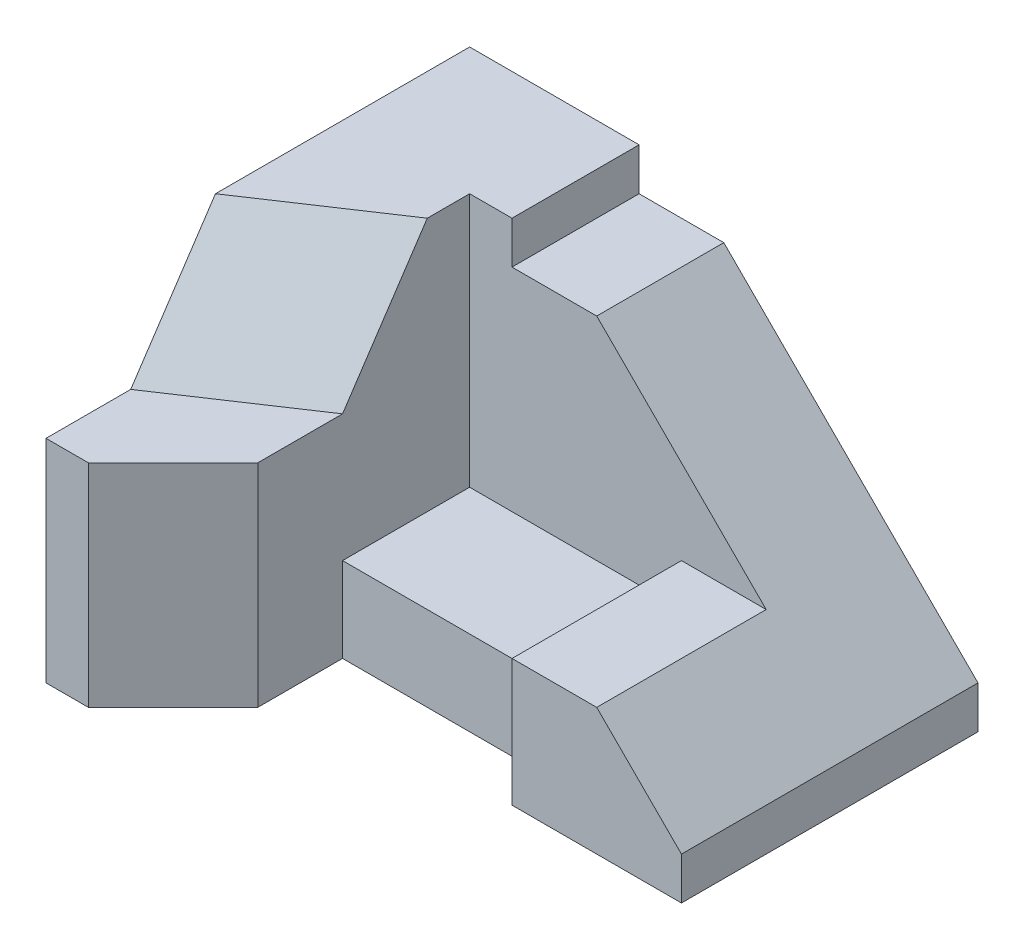
from build123d import *

# Parameters (mm, degrees)
BOSS_EXTRUDE1_DEPTH       = 80
SKETCH2_W                 = 60
SKETCH2_H                 = 80
BOSS_EXTRUDE6_DEPTH       = 10
CUT_EXTRUDE3_DEPTH        = 149
BOSS_EXTRUDE7_DEPTH       = 20
SKETCH11_W                = 100
SKETCH11_H                = 80
CUT_EXTRUDE4_DEPTH        = 20
CUT_EXTRUDE5_DEPTH        = 20
SKETCH14_W                = 24.037008503
SKETCH14_H                = 50
CUT_EXTRUDE6_DEPTH        = 29
SKETCH15_W                = 46.666666667
SKETCH15_H                = 50
CUT_EXTRUDE7_DEPTH        = 29
SKETCH16_W                = 20
SKETCH16_H                = 30
BOSS_EXTRUDE8_DEPTH       = 70
BOSS_EXTRUDE10_DEPTH      = 30
SKETCH21_W                = 43.205783384
SKETCH21_H                = 74.052806938
CUT_EXTRUDE9_DEPTH        = 30
SKETCH22_W                = 30
SKETCH22_H                = 20
CUT_EXTRUDE10_DEPTH       = 30
BOSS_EXTRUDE11_DEPTH      = 30
BOSS_EXTRUDE12_DEPTH      = 40
BOSS_EXTRUDE12_DEPTH_BACK = 30
SKETCH25_W                = 50
SKETCH25_H                = 20
BOSS_EXTRUDE13_DEPTH      = 60
BOSS_EXTRUDE16_DEPTH      = 50
BOSS_EXTRUDE17_DEPTH      = 20


with BuildPart() as part:
    # Sketch1 → Boss-Extrude1 (new body)
    with BuildSketch(Plane(origin=(0, 0, 0), x_dir=(1, 0, 0), z_dir=(0, 1, 0))):
        Polygon((0, 0), (0, 60), (40, 60), (40, 30), (30, 30), (30, 20), align=None)
    extrude(amount=BOSS_EXTRUDE1_DEPTH)

    # Sketch2 → Boss-Extrude6 (add)
    with BuildSketch(Plane.ZY):
        with Locations((-30, 40)):
            Rectangle(SKETCH2_W, SKETCH2_H)
        Polygon((40, 0), (0, 0), (0, 80), (20, 50), (40, 50), align=None)
    extrude(amount=-BOSS_EXTRUDE6_DEPTH)

    # Sketch8 → Cut-Extrude3 (cut)
    with BuildSketch(Plane(origin=(18.823529412, 18.823529412, 28.235294118), x_dir=(0.874474632, -0.269069118, -0.403603676), z_dir=(0.48507125, 0.48507125, 0.727606875))):
        Polygon((-21.525529408, 30.508510792), (12.780783086, 41.602514717), (12.780783086, 77.658027472), (-21.525529408, 66.564023547), align=None)
    extrude(amount=CUT_EXTRUDE3_DEPTH, mode=Mode.SUBTRACT)

    # Sketch10 → Boss-Extrude7 (add)
    with BuildSketch(Plane(origin=(18.823529412, 18.823529412, 28.235294118), x_dir=(0.874474632, -0.269069118, -0.403603676), z_dir=(0.48507125, 0.48507125, 0.727606875))):
        Polygon((-21.525529408, 30.508510792), (12.780783086, 41.602514717), (12.780783086, 77.658027472), (-21.525529408, 66.564023547), align=None)
    extrude(amount=-BOSS_EXTRUDE7_DEPTH)

    # Sketch11 → Cut-Extrude4 (cut)
    with BuildSketch(Plane.ZY):
        with Locations((-10, 40)):
            Rectangle(SKETCH11_W, SKETCH11_H)
    extrude(amount=CUT_EXTRUDE4_DEPTH, mode=Mode.SUBTRACT)

    # Sketch12 → Cut-Extrude5 (cut)
    with BuildSketch(Plane(origin=(0, 50, 0), x_dir=(1, 0, 0), z_dir=(0, 1, 0))):
        Polygon((0, -20), (10, -13.333333333), (10, -40), (0, -40), align=None)
    extrude(amount=CUT_EXTRUDE5_DEPTH, mode=Mode.SUBTRACT)

    # Sketch14 → Cut-Extrude6 (cut)
    with BuildSketch(Plane(origin=(0, 0, 0), x_dir=(0.832050294, 0, -0.554700196), z_dir=(0.554700196, 0, 0.832050294))):
        with Locations((24.037008504, 25)):
            Rectangle(SKETCH14_W, SKETCH14_H)
    extrude(amount=CUT_EXTRUDE6_DEPTH, mode=Mode.SUBTRACT)

    # Sketch15 → Cut-Extrude7 (cut)
    with BuildSketch(Plane(origin=(10, 0, 0), x_dir=(0, 0, -1), z_dir=(1, 0, 0))):
        with Locations((-16.666666666, 25)):
            Rectangle(SKETCH15_W, SKETCH15_H)
    extrude(amount=CUT_EXTRUDE7_DEPTH, mode=Mode.SUBTRACT)

    # Sketch16 → Boss-Extrude8 (add)
    with BuildSketch(Plane(origin=(0, 70, 0), x_dir=(1, 0, 0), z_dir=(0, 1, 0))):
        with Locations((50, 45)):
            Rectangle(SKETCH16_W, SKETCH16_H)
    extrude(amount=-BOSS_EXTRUDE8_DEPTH)

    # Sketch17 → Boss-Extrude10 (add)
    with BuildSketch(Plane(origin=(0, 0, -60), x_dir=(-1, 0, 0), z_dir=(0, 0, -1))):
        Polygon((-80, 10), (-80, 0), (-60, 0), (-60, 70), (-100, 10), align=None)
    extrude(amount=-BOSS_EXTRUDE10_DEPTH)

    # Sketch21 → Cut-Extrude9 (cut)
    with BuildSketch(Plane.XY.offset(-30)):
        with Locations((81.602891692, 32.973596531)):
            Rectangle(SKETCH21_W, SKETCH21_H)
    extrude(amount=-CUT_EXTRUDE9_DEPTH, mode=Mode.SUBTRACT)

    # Sketch22 → Cut-Extrude10 (cut)
    with BuildSketch(Plane.XY.offset(-30)):
        with Locations((45, 10)):
            Rectangle(SKETCH22_W, SKETCH22_H)
    extrude(amount=-CUT_EXTRUDE10_DEPTH, mode=Mode.SUBTRACT)

    # Sketch23 → Boss-Extrude11 (add)
    with BuildSketch(Plane.XY.offset(-30)):
        Polygon((60, 70), (100, 30), (80, 30), (80, 20), (60, 20), align=None)
    extrude(amount=-BOSS_EXTRUDE11_DEPTH)

    # Sketch24 → Boss-Extrude12 (add, two sides)
    with BuildSketch(Plane.XY.offset(-30)) as boss_extrude12_sk:
        Polygon((100, 30), (120, 10), (120, 0), (80, 0), (80, 30), align=None)
    extrude(amount=BOSS_EXTRUDE12_DEPTH)
    extrude(boss_extrude12_sk.sketch, amount=-BOSS_EXTRUDE12_DEPTH_BACK)

    # Sketch25 → Boss-Extrude13 (add)
    with BuildSketch(Plane(origin=(0, 0, -60), x_dir=(-1, 0, 0), z_dir=(0, 0, -1))):
        with Locations((-55, 10)):
            Rectangle(SKETCH25_W, SKETCH25_H)
    extrude(amount=-BOSS_EXTRUDE13_DEPTH)

    # Sketch28 → Boss-Extrude16 (add)
    with BuildSketch(Plane(origin=(0, 0, 0), x_dir=(-1, 0, 0), z_dir=(0, -1, 0))):
        Polygon((-10, 6.666666667), (-30, 20), (-10, -6.666666667), align=None)
        Polygon((-10, -6.666666667), (-30, 20), (-30, 0), (-30, -20), (-10, -40), align=None)
    extrude(amount=-BOSS_EXTRUDE16_DEPTH)

    # Sketch29 → Boss-Extrude17 (add)
    with BuildSketch(Plane(origin=(30, 0, 0), x_dir=(0, 0, -1), z_dir=(1, 0, 0))):
        Polygon((0, 50), (20, 50), (20, 80), align=None)
    extrude(amount=-BOSS_EXTRUDE17_DEPTH)


solid = part.part
